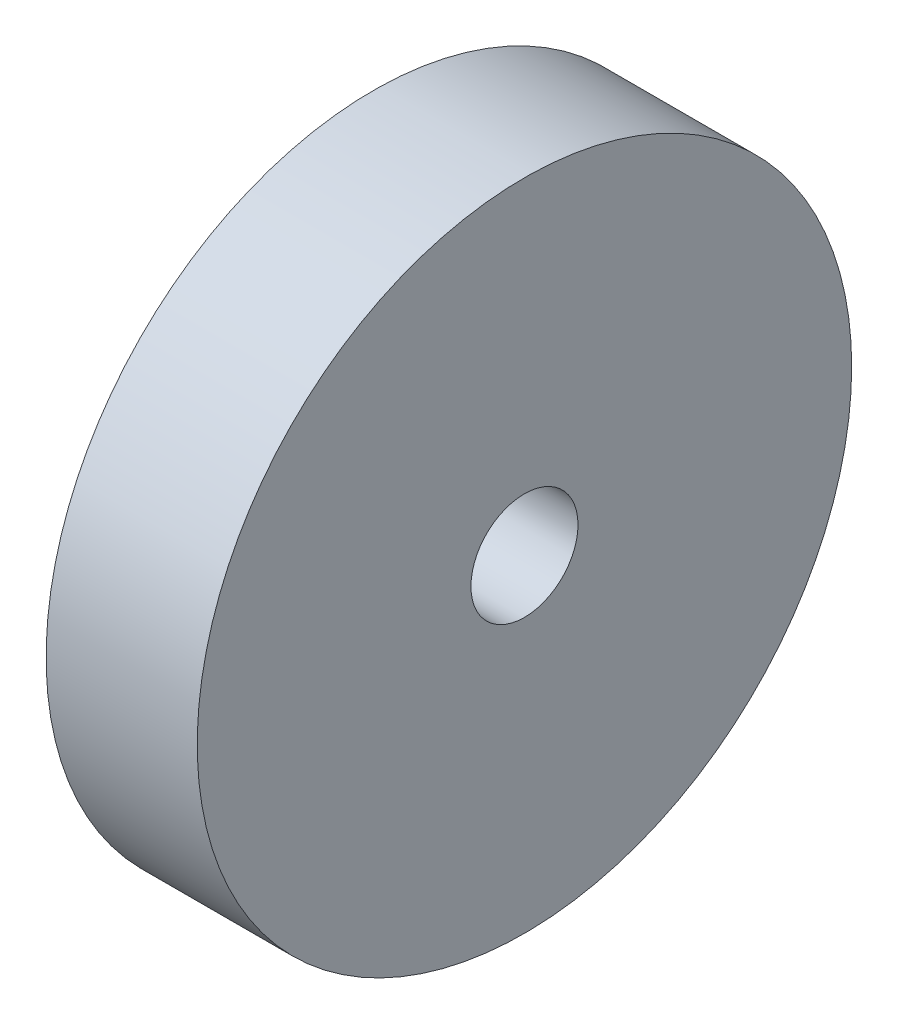
from build123d import *

# Parameters (mm, degrees)
SKETCH2_R                = 11
BOSS_EXTRUDE1_DEPTH      = 5.08
M3_CLEARANCE_HOLE1_D     = 3.6
M3_CLEARANCE_HOLE1_DEPTH = 5.08


with BuildPart() as part:
    # Sketch2 → Boss-Extrude1 (new body)
    with BuildSketch(Plane(origin=(0, 0, 0), x_dir=(0, 0, -1), z_dir=(1, 0, 0))):
        Circle(SKETCH2_R)
    extrude(amount=BOSS_EXTRUDE1_DEPTH)

    # M3 Clearance Hole1
    with Locations(Plane.ZY):
        with Locations((0, 0)):
            Hole(M3_CLEARANCE_HOLE1_D / 2, depth=M3_CLEARANCE_HOLE1_DEPTH)


solid = part.part
